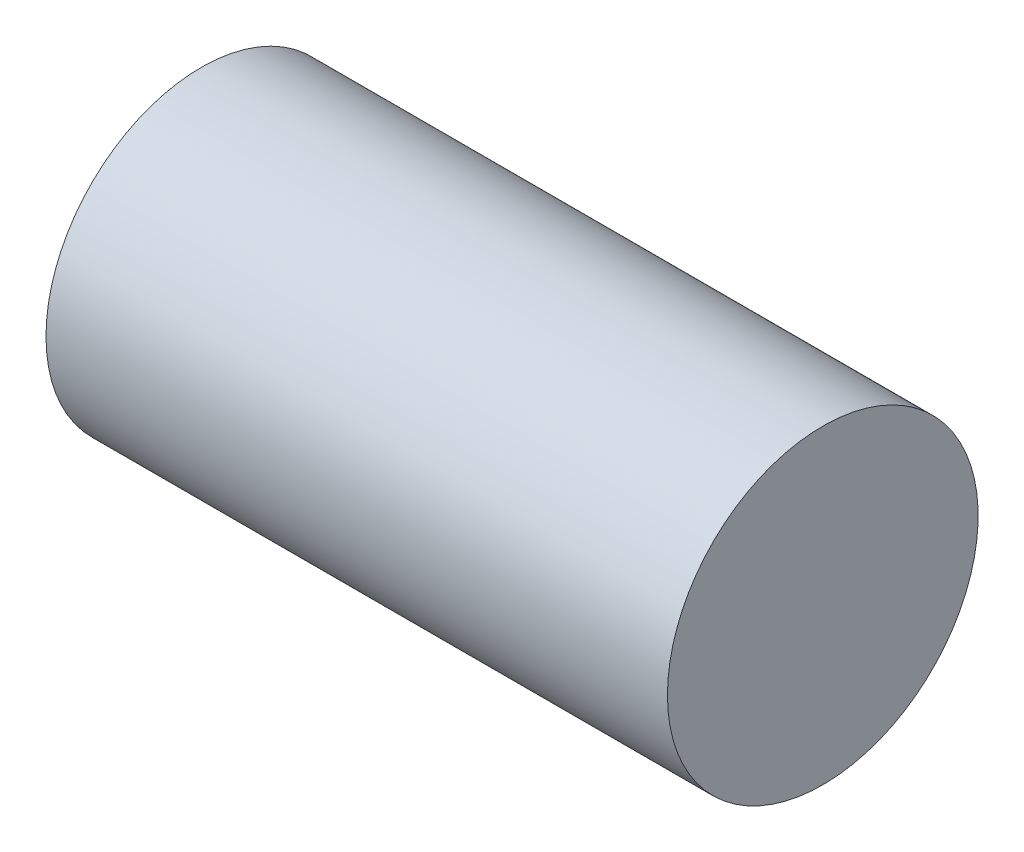
from build123d import *

# Parameters (mm, degrees)
SCHIZZO1_W = 40
SCHIZZO1_H = 10


with BuildPart() as part:
    # Schizzo1 → Rivoluzione1 (revolve)
    with BuildSketch(Plane.XY):
        with Locations((20, 5)):
            Rectangle(SCHIZZO1_W, SCHIZZO1_H)
    revolve(axis=Axis((0, 10, 0), (1, 0, 0)))


solid = part.part
